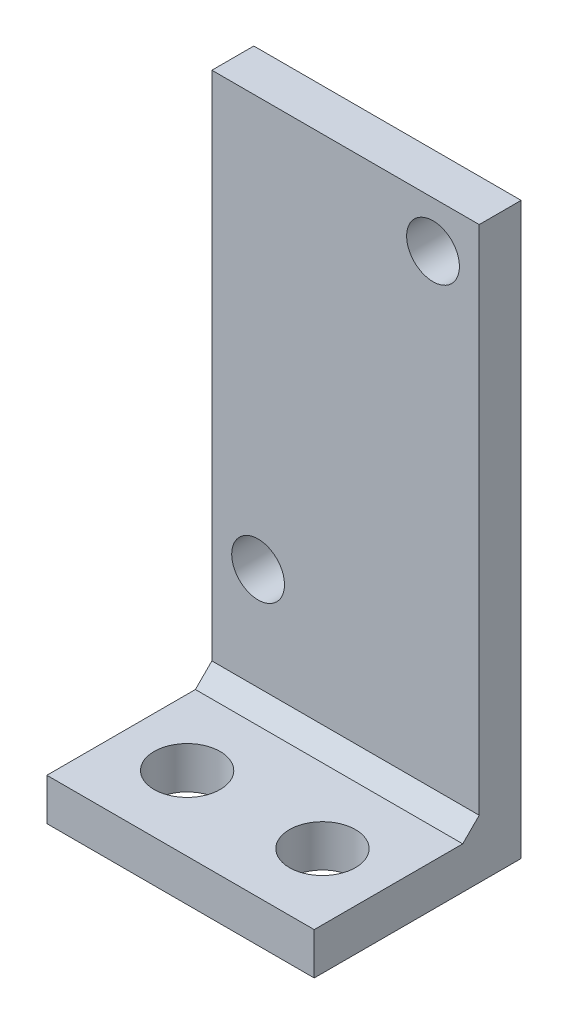
from build123d import *

# Parameters (mm, degrees)
SKETCH1_W           = 16.2
SKETCH1_H           = 34.54
BOSS_EXTRUDE1_DEPTH = 2.54
SKETCH2_W           = 16.2
SKETCH2_H           = 2.54
BOSS_EXTRUDE2_DEPTH = 10
CHAMFER1_SIZE       = 1
SKETCH4_R           = 1.6
CUT_EXTRUDE1_DEPTH  = 2.54
SKETCH5_R           = 2
CUT_EXTRUDE2_DEPTH  = 3.54


with BuildPart() as part:
    # Sketch1 → Boss-Extrude1 (new body)
    with BuildSketch(Plane.XY):
        with Locations((8.1, 17.27)):
            Rectangle(SKETCH1_W, SKETCH1_H)
    extrude(amount=BOSS_EXTRUDE1_DEPTH)

    # Sketch2 → Boss-Extrude2 (add)
    with BuildSketch(Plane.XY.offset(2.54)):
        with Locations((8.1, 1.27)):
            Rectangle(SKETCH2_W, SKETCH2_H)
    extrude(amount=BOSS_EXTRUDE2_DEPTH)

    # Chamfer1
    chamfer1_edges = [part.edges().sort_by_distance(p)[0] for p in [
        (8.1, 2.54, 2.54),
    ]]
    chamfer(chamfer1_edges, length=CHAMFER1_SIZE)

    # Sketch4 → Cut-Extrude1 (cut)
    with BuildSketch(Plane(origin=(0, 0, 0), x_dir=(-1, 0, 0), z_dir=(0, 0, -1))):
        with Locations((-13.4, 31.74)):
            Circle(SKETCH4_R)
        with Locations((-2.8, 9.74)):
            Circle(SKETCH4_R)
    extrude(amount=-CUT_EXTRUDE1_DEPTH, mode=Mode.SUBTRACT)

    # Sketch5 → Cut-Extrude2 (cut, through all)
    with BuildSketch(Plane(origin=(0, 2.54, 0), x_dir=(1, 0, 0), z_dir=(0, 1, 0))):
        with Locations((12.2, -8.04)):
            Circle(SKETCH5_R)
        with Locations((4, -8.04)):
            Circle(SKETCH5_R)
    extrude(amount=-CUT_EXTRUDE2_DEPTH, mode=Mode.SUBTRACT)


solid = part.part
